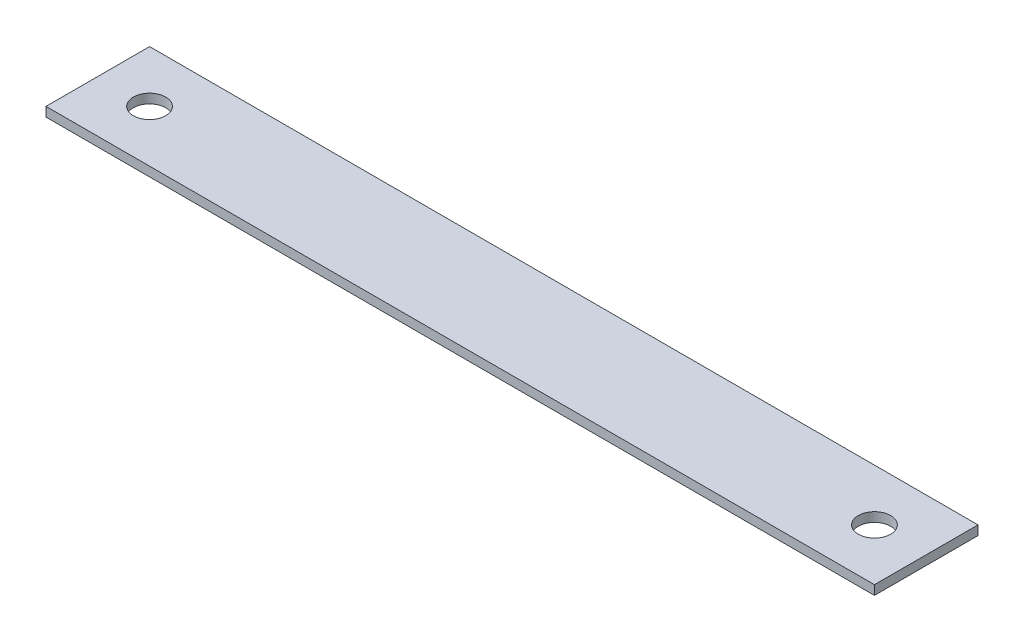
from build123d import *

# Parameters (mm, degrees)
SKETCH1_W           = 203.2
SKETCH1_H           = 25.4
BOSS_EXTRUDE1_DEPTH = 2.286
SKETCH2_R           = 3.96875
CUT_EXTRUDE1_DEPTH  = 3.286


with BuildPart() as part:
    # Sketch1 → Boss-Extrude1 (new body)
    with BuildSketch(Plane(origin=(0, 0, 0), x_dir=(1, 0, 0), z_dir=(0, 1, 0))):
        with Locations((101.6, 12.7)):
            Rectangle(SKETCH1_W, SKETCH1_H)
    extrude(amount=BOSS_EXTRUDE1_DEPTH)

    # Sketch2 → Cut-Extrude1 (cut, through all)
    with BuildSketch(Plane(origin=(0, 2.286, 0), x_dir=(1, 0, 0), z_dir=(0, 1, 0))):
        with Locations((12.7, 12.7)):
            Circle(SKETCH2_R)
        with Locations((190.5, 12.7)):
            Circle(SKETCH2_R)
    extrude(amount=-CUT_EXTRUDE1_DEPTH, mode=Mode.SUBTRACT)


solid = part.part
